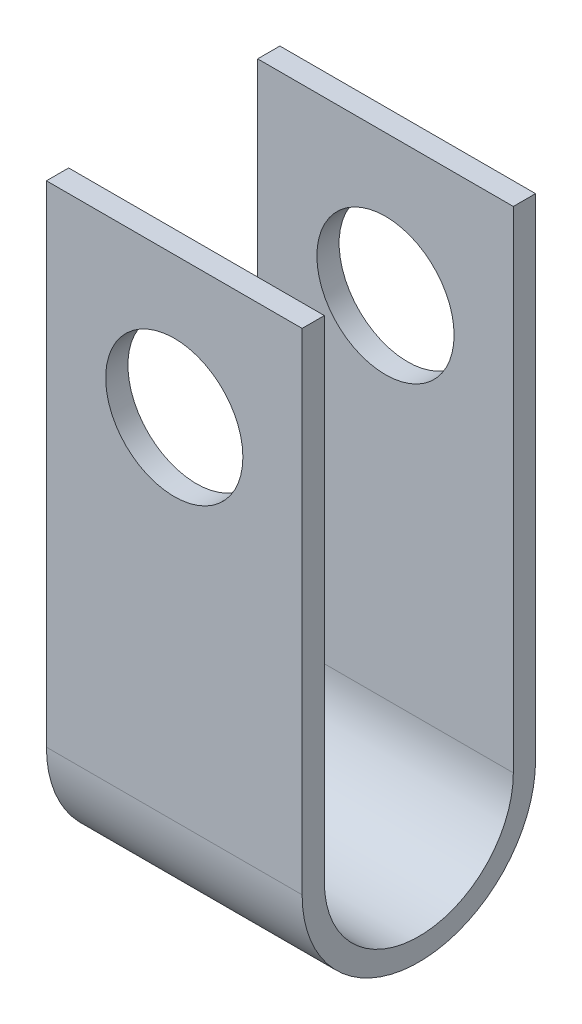
from build123d import *

# Parameters (mm, degrees)
BOSS_EXTRUDE1_DEPTH = 11.5
SKETCH3_R           = 6.171796323
CUT_EXTRUDE1_DEPTH  = 22


with BuildPart() as part:
    # Sketch2 → Boss-Extrude1 (new body, symmetric)
    with BuildSketch(Plane(origin=(0, 0, 0), x_dir=(0, 0, -1), z_dir=(1, 0, 0))):
        with BuildLine():
            Line((-10.5, -13.355315719), (-10.5, 30.769844031))
            Line((-10.5, 30.769844031), (-8.5, 30.769844031))
            Line((-8.5, 30.769844031), (-8.5, -13.355315719))
            ThreePointArc((-8.5, -13.355315719), (0, -21.855315719), (8.5, -13.355315719))
            Line((8.5, -13.355315719), (8.5, 30.769844031))
            Line((8.5, 30.769844031), (10.5, 30.769844031))
            Line((10.5, 30.769844031), (10.5, -13.355315719))
            ThreePointArc((10.5, -13.355315719), (0, -23.855315719), (-10.5, -13.355315719))
        make_face()
    extrude(amount=BOSS_EXTRUDE1_DEPTH, both=True)

    # Sketch3 → Cut-Extrude1 (cut, through all)
    with BuildSketch(Plane.XY.offset(10.5)):
        with Locations((0, 18.082496022)):
            Circle(SKETCH3_R)
    extrude(amount=-CUT_EXTRUDE1_DEPTH, mode=Mode.SUBTRACT)


solid = part.part
